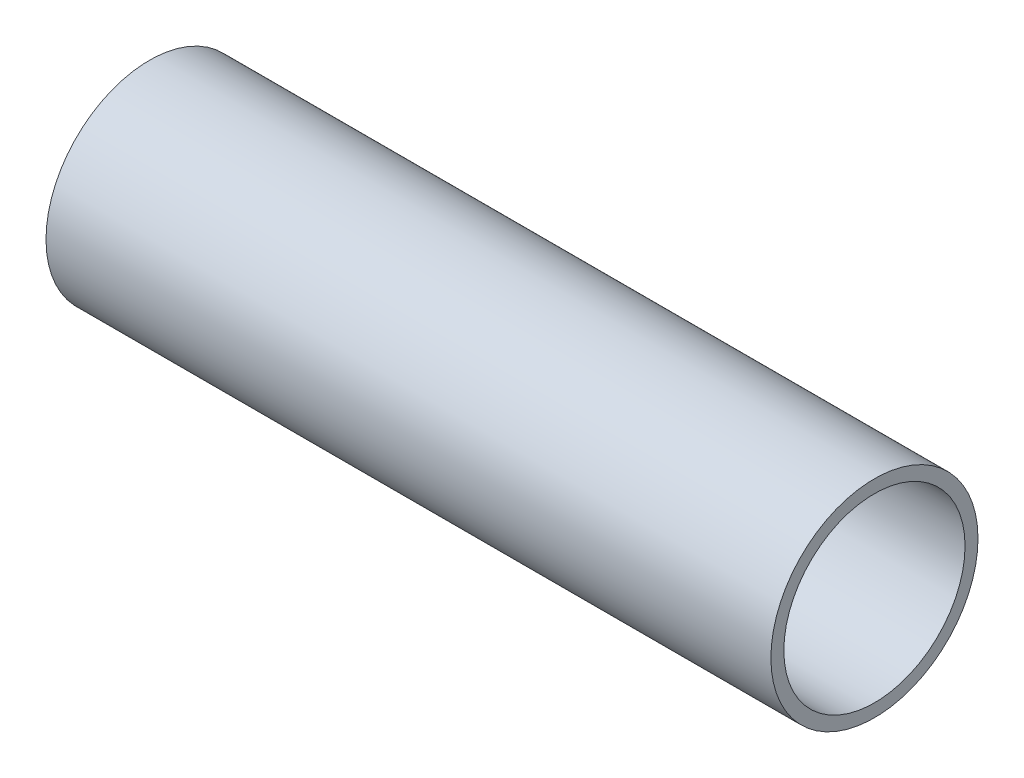
from build123d import *

# Parameters (mm, degrees)
SKETCH1_R           = 25.4
SKETCH1_R_2         = 22.225
BOSS_EXTRUDE1_DEPTH = 177.8


with BuildPart() as part:
    # Sketch1 → Boss-Extrude1 (new body)
    with BuildSketch(Plane(origin=(0, 0, 0), x_dir=(0, 0, -1), z_dir=(1, 0, 0))):
        Circle(SKETCH1_R)
        Circle(SKETCH1_R_2, mode=Mode.SUBTRACT)
    extrude(amount=BOSS_EXTRUDE1_DEPTH)


solid = part.part
